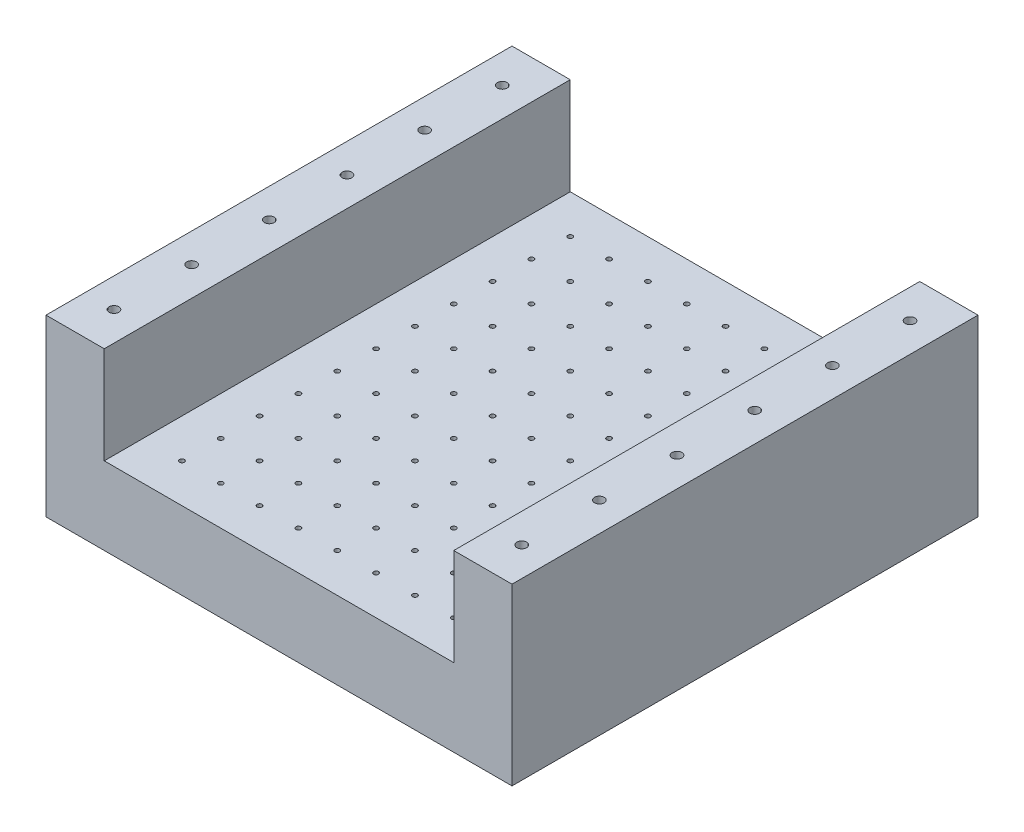
from build123d import *

# Parameters (mm, degrees)
SKETCH2_W           = 609.6
SKETCH2_H           = 609.6
BOSS_EXTRUDE1_DEPTH = 101.6
SKETCH4_W           = 76.2
SKETCH4_H           = 609.6
BOSS_EXTRUDE2_DEPTH = 127
SKETCH5_R           = 6.35
CUT_EXTRUDE1_DEPTH  = 50.8
LPATTERN1_COUNT     = 2
LPATTERN1_PITCH     = 533.4
SKETCH6_R           = 3.175
CUT_EXTRUDE2_DEPTH  = 50.8


with BuildPart() as part:
    # Sketch2 → Boss-Extrude1 (new body)
    with BuildSketch(Plane(origin=(0, 0, 0), x_dir=(1, 0, 0), z_dir=(0, 1, 0))):
        with Locations((408.853418399, -267.425277164)):
            Rectangle(SKETCH2_W, SKETCH2_H)
    extrude(amount=BOSS_EXTRUDE1_DEPTH)

    # Sketch4 → Boss-Extrude2 (add)
    with BuildSketch(Plane(origin=(0, 101.6, 0), x_dir=(1, 0, 0), z_dir=(0, 1, 0))):
        with Locations((142.153418399, -267.425277164)):
            Rectangle(SKETCH4_W, SKETCH4_H)
        with Locations((675.553418399, -267.425277164)):
            Rectangle(SKETCH4_W, SKETCH4_H)
    extrude(amount=BOSS_EXTRUDE2_DEPTH)

    # Sketch5 → Cut-Extrude1 (cut)
    with BuildSketch(Plane(origin=(0, 228.6, 0), x_dir=(1, 0, 0), z_dir=(0, 1, 0))):
        with Locations(Location((142.153418399, -13.425277164, 0), (0, 0, 270))):  # turned: the seam where the file's is
            Circle(SKETCH5_R)
        with Locations(Location((142.153418399, -115.025277164, 0), (0, 0, 270))):  # turned: the seam where the file's is
            Circle(SKETCH5_R)
        with Locations(Location((142.153418399, -216.625277164, 0), (0, 0, 270))):  # turned: the seam where the file's is
            Circle(SKETCH5_R)
        with Locations(Location((142.153418399, -318.225277164, 0), (0, 0, 270))):  # turned: the seam where the file's is
            Circle(SKETCH5_R)
        with Locations(Location((142.153418399, -419.825277164, 0), (0, 0, 270))):  # turned: the seam where the file's is
            Circle(SKETCH5_R)
        with Locations(Location((142.153418399, -521.425277164, 0), (0, 0, 270))):  # turned: the seam where the file's is
            Circle(SKETCH5_R)
    cut_extrude1 = extrude(amount=-CUT_EXTRUDE1_DEPTH, mode=Mode.SUBTRACT)

    # LPattern1: Cut-Extrude1 ×2
    with Locations(*[(i * LPATTERN1_PITCH, 0, 0) for i in range(1, LPATTERN1_COUNT)]):
        add(cut_extrude1, mode=Mode.SUBTRACT)

    # Sketch6 → Cut-Extrude2 (cut)
    with BuildSketch(Plane(origin=(0, 101.6, 0), x_dir=(1, 0, 0), z_dir=(0, 1, 0))):
        with Locations(Location((231.053418399, -521.425277164, 0), (0, 0, 270))):  # turned: the seam where the file's is
            Circle(SKETCH6_R)
        with Locations(Location((231.053418399, -470.625277164, 0), (0, 0, 270))):  # turned: the seam where the file's is
            Circle(SKETCH6_R)
        with Locations(Location((231.053418399, -419.825277164, 0), (0, 0, 270))):  # turned: the seam where the file's is
            Circle(SKETCH6_R)
        with Locations(Location((231.053418399, -369.025277164, 0), (0, 0, 270))):  # turned: the seam where the file's is
            Circle(SKETCH6_R)
        with Locations(Location((231.053418399, -318.225277164, 0), (0, 0, 270))):  # turned: the seam where the file's is
            Circle(SKETCH6_R)
        with Locations(Location((231.053418399, -267.425277164, 0), (0, 0, 270))):  # turned: the seam where the file's is
            Circle(SKETCH6_R)
        with Locations(Location((231.053418399, -216.625277164, 0), (0, 0, 270))):  # turned: the seam where the file's is
            Circle(SKETCH6_R)
        with Locations(Location((231.053418399, -165.825277164, 0), (0, 0, 270))):  # turned: the seam where the file's is
            Circle(SKETCH6_R)
        with Locations(Location((231.053418399, -115.025277164, 0), (0, 0, 270))):  # turned: the seam where the file's is
            Circle(SKETCH6_R)
        with Locations(Location((231.053418399, -64.225277164, 0), (0, 0, 270))):  # turned: the seam where the file's is
            Circle(SKETCH6_R)
        with Locations(Location((231.053418399, -13.425277164, 0), (0, 0, 270))):  # turned: the seam where the file's is
            Circle(SKETCH6_R)
        with Locations(Location((281.853418399, -521.425277164, 0), (0, 0, 270))):  # turned: the seam where the file's is
            Circle(SKETCH6_R)
        with Locations(Location((281.853418399, -470.625277164, 0), (0, 0, 270))):  # turned: the seam where the file's is
            Circle(SKETCH6_R)
        with Locations(Location((281.853418399, -419.825277164, 0), (0, 0, 270))):  # turned: the seam where the file's is
            Circle(SKETCH6_R)
        with Locations(Location((281.853418399, -369.025277164, 0), (0, 0, 270))):  # turned: the seam where the file's is
            Circle(SKETCH6_R)
        with Locations(Location((281.853418399, -318.225277164, 0), (0, 0, 270))):  # turned: the seam where the file's is
            Circle(SKETCH6_R)
        with Locations(Location((281.853418399, -267.425277164, 0), (0, 0, 270))):  # turned: the seam where the file's is
            Circle(SKETCH6_R)
        with Locations(Location((281.853418399, -216.625277164, 0), (0, 0, 270))):  # turned: the seam where the file's is
            Circle(SKETCH6_R)
        with Locations(Location((281.853418399, -165.825277164, 0), (0, 0, 270))):  # turned: the seam where the file's is
            Circle(SKETCH6_R)
        with Locations(Location((281.853418399, -115.025277164, 0), (0, 0, 270))):  # turned: the seam where the file's is
            Circle(SKETCH6_R)
        with Locations(Location((281.853418399, -64.225277164, 0), (0, 0, 270))):  # turned: the seam where the file's is
            Circle(SKETCH6_R)
        with Locations(Location((281.853418399, -13.425277164, 0), (0, 0, 270))):  # turned: the seam where the file's is
            Circle(SKETCH6_R)
        with Locations(Location((332.653418399, -521.425277164, 0), (0, 0, 270))):  # turned: the seam where the file's is
            Circle(SKETCH6_R)
        with Locations(Location((332.653418399, -470.625277164, 0), (0, 0, 270))):  # turned: the seam where the file's is
            Circle(SKETCH6_R)
        with Locations(Location((332.653418399, -419.825277164, 0), (0, 0, 270))):  # turned: the seam where the file's is
            Circle(SKETCH6_R)
        with Locations(Location((332.653418399, -369.025277164, 0), (0, 0, 270))):  # turned: the seam where the file's is
            Circle(SKETCH6_R)
        with Locations(Location((332.653418399, -318.225277164, 0), (0, 0, 270))):  # turned: the seam where the file's is
            Circle(SKETCH6_R)
        with Locations(Location((332.653418399, -267.425277164, 0), (0, 0, 270))):  # turned: the seam where the file's is
            Circle(SKETCH6_R)
        with Locations(Location((332.653418399, -216.625277164, 0), (0, 0, 270))):  # turned: the seam where the file's is
            Circle(SKETCH6_R)
        with Locations(Location((332.653418399, -165.825277164, 0), (0, 0, 270))):  # turned: the seam where the file's is
            Circle(SKETCH6_R)
        with Locations(Location((332.653418399, -115.025277164, 0), (0, 0, 270))):  # turned: the seam where the file's is
            Circle(SKETCH6_R)
        with Locations(Location((332.653418399, -64.225277164, 0), (0, 0, 270))):  # turned: the seam where the file's is
            Circle(SKETCH6_R)
        with Locations(Location((332.653418399, -13.425277164, 0), (0, 0, 270))):  # turned: the seam where the file's is
            Circle(SKETCH6_R)
        with Locations(Location((383.453418399, -521.425277164, 0), (0, 0, 270))):  # turned: the seam where the file's is
            Circle(SKETCH6_R)
        with Locations(Location((383.453418399, -470.625277164, 0), (0, 0, 270))):  # turned: the seam where the file's is
            Circle(SKETCH6_R)
        with Locations(Location((383.453418399, -419.825277164, 0), (0, 0, 270))):  # turned: the seam where the file's is
            Circle(SKETCH6_R)
        with Locations(Location((383.453418399, -369.025277164, 0), (0, 0, 270))):  # turned: the seam where the file's is
            Circle(SKETCH6_R)
        with Locations(Location((383.453418399, -318.225277164, 0), (0, 0, 270))):  # turned: the seam where the file's is
            Circle(SKETCH6_R)
        with Locations(Location((383.453418399, -267.425277164, 0), (0, 0, 270))):  # turned: the seam where the file's is
            Circle(SKETCH6_R)
        with Locations(Location((383.453418399, -216.625277164, 0), (0, 0, 270))):  # turned: the seam where the file's is
            Circle(SKETCH6_R)
        with Locations(Location((383.453418399, -165.825277164, 0), (0, 0, 270))):  # turned: the seam where the file's is
            Circle(SKETCH6_R)
        with Locations(Location((383.453418399, -115.025277164, 0), (0, 0, 270))):  # turned: the seam where the file's is
            Circle(SKETCH6_R)
        with Locations(Location((383.453418399, -64.225277164, 0), (0, 0, 270))):  # turned: the seam where the file's is
            Circle(SKETCH6_R)
        with Locations(Location((383.453418399, -13.425277164, 0), (0, 0, 270))):  # turned: the seam where the file's is
            Circle(SKETCH6_R)
        with Locations(Location((434.253418399, -521.425277164, 0), (0, 0, 270))):  # turned: the seam where the file's is
            Circle(SKETCH6_R)
        with Locations(Location((434.253418399, -470.625277164, 0), (0, 0, 270))):  # turned: the seam where the file's is
            Circle(SKETCH6_R)
        with Locations(Location((434.253418399, -419.825277164, 0), (0, 0, 270))):  # turned: the seam where the file's is
            Circle(SKETCH6_R)
        with Locations(Location((434.253418399, -369.025277164, 0), (0, 0, 270))):  # turned: the seam where the file's is
            Circle(SKETCH6_R)
        with Locations(Location((434.253418399, -318.225277164, 0), (0, 0, 270))):  # turned: the seam where the file's is
            Circle(SKETCH6_R)
        with Locations(Location((434.253418399, -267.425277164, 0), (0, 0, 270))):  # turned: the seam where the file's is
            Circle(SKETCH6_R)
        with Locations(Location((434.253418399, -216.625277164, 0), (0, 0, 270))):  # turned: the seam where the file's is
            Circle(SKETCH6_R)
        with Locations(Location((434.253418399, -165.825277164, 0), (0, 0, 270))):  # turned: the seam where the file's is
            Circle(SKETCH6_R)
        with Locations(Location((434.253418399, -115.025277164, 0), (0, 0, 270))):  # turned: the seam where the file's is
            Circle(SKETCH6_R)
        with Locations(Location((434.253418399, -64.225277164, 0), (0, 0, 270))):  # turned: the seam where the file's is
            Circle(SKETCH6_R)
        with Locations(Location((434.253418399, -13.425277164, 0), (0, 0, 270))):  # turned: the seam where the file's is
            Circle(SKETCH6_R)
        with Locations(Location((485.053418399, -521.425277164, 0), (0, 0, 270))):  # turned: the seam where the file's is
            Circle(SKETCH6_R)
        with Locations(Location((485.053418399, -470.625277164, 0), (0, 0, 270))):  # turned: the seam where the file's is
            Circle(SKETCH6_R)
        with Locations(Location((485.053418399, -419.825277164, 0), (0, 0, 270))):  # turned: the seam where the file's is
            Circle(SKETCH6_R)
        with Locations(Location((485.053418399, -369.025277164, 0), (0, 0, 270))):  # turned: the seam where the file's is
            Circle(SKETCH6_R)
        with Locations(Location((485.053418399, -318.225277164, 0), (0, 0, 270))):  # turned: the seam where the file's is
            Circle(SKETCH6_R)
        with Locations(Location((485.053418399, -267.425277164, 0), (0, 0, 270))):  # turned: the seam where the file's is
            Circle(SKETCH6_R)
        with Locations(Location((485.053418399, -216.625277164, 0), (0, 0, 270))):  # turned: the seam where the file's is
            Circle(SKETCH6_R)
        with Locations(Location((485.053418399, -165.825277164, 0), (0, 0, 270))):  # turned: the seam where the file's is
            Circle(SKETCH6_R)
        with Locations(Location((485.053418399, -115.025277164, 0), (0, 0, 270))):  # turned: the seam where the file's is
            Circle(SKETCH6_R)
        with Locations(Location((485.053418399, -64.225277164, 0), (0, 0, 270))):  # turned: the seam where the file's is
            Circle(SKETCH6_R)
        with Locations(Location((485.053418399, -13.425277164, 0), (0, 0, 270))):  # turned: the seam where the file's is
            Circle(SKETCH6_R)
        with Locations(Location((535.853418399, -521.425277164, 0), (0, 0, 270))):  # turned: the seam where the file's is
            Circle(SKETCH6_R)
        with Locations(Location((535.853418399, -470.625277164, 0), (0, 0, 270))):  # turned: the seam where the file's is
            Circle(SKETCH6_R)
        with Locations(Location((535.853418399, -419.825277164, 0), (0, 0, 270))):  # turned: the seam where the file's is
            Circle(SKETCH6_R)
        with Locations(Location((535.853418399, -369.025277164, 0), (0, 0, 270))):  # turned: the seam where the file's is
            Circle(SKETCH6_R)
        with Locations(Location((535.853418399, -318.225277164, 0), (0, 0, 270))):  # turned: the seam where the file's is
            Circle(SKETCH6_R)
        with Locations(Location((535.853418399, -267.425277164, 0), (0, 0, 270))):  # turned: the seam where the file's is
            Circle(SKETCH6_R)
        with Locations(Location((535.853418399, -216.625277164, 0), (0, 0, 270))):  # turned: the seam where the file's is
            Circle(SKETCH6_R)
        with Locations(Location((535.853418399, -165.825277164, 0), (0, 0, 270))):  # turned: the seam where the file's is
            Circle(SKETCH6_R)
        with Locations(Location((535.853418399, -115.025277164, 0), (0, 0, 270))):  # turned: the seam where the file's is
            Circle(SKETCH6_R)
        with Locations(Location((535.853418399, -64.225277164, 0), (0, 0, 270))):  # turned: the seam where the file's is
            Circle(SKETCH6_R)
        with Locations(Location((535.853418399, -13.425277164, 0), (0, 0, 270))):  # turned: the seam where the file's is
            Circle(SKETCH6_R)
        with Locations(Location((586.653418399, -521.425277164, 0), (0, 0, 270))):  # turned: the seam where the file's is
            Circle(SKETCH6_R)
        with Locations(Location((586.653418399, -470.625277164, 0), (0, 0, 270))):  # turned: the seam where the file's is
            Circle(SKETCH6_R)
        with Locations(Location((586.653418399, -419.825277164, 0), (0, 0, 270))):  # turned: the seam where the file's is
            Circle(SKETCH6_R)
        with Locations(Location((586.653418399, -369.025277164, 0), (0, 0, 270))):  # turned: the seam where the file's is
            Circle(SKETCH6_R)
        with Locations(Location((586.653418399, -318.225277164, 0), (0, 0, 270))):  # turned: the seam where the file's is
            Circle(SKETCH6_R)
        with Locations(Location((586.653418399, -267.425277164, 0), (0, 0, 270))):  # turned: the seam where the file's is
            Circle(SKETCH6_R)
        with Locations(Location((586.653418399, -216.625277164, 0), (0, 0, 270))):  # turned: the seam where the file's is
            Circle(SKETCH6_R)
        with Locations(Location((586.653418399, -165.825277164, 0), (0, 0, 270))):  # turned: the seam where the file's is
            Circle(SKETCH6_R)
        with Locations(Location((586.653418399, -115.025277164, 0), (0, 0, 270))):  # turned: the seam where the file's is
            Circle(SKETCH6_R)
        with Locations(Location((586.653418399, -64.225277164, 0), (0, 0, 270))):  # turned: the seam where the file's is
            Circle(SKETCH6_R)
        with Locations(Location((586.653418399, -13.425277164, 0), (0, 0, 270))):  # turned: the seam where the file's is
            Circle(SKETCH6_R)
    extrude(amount=-CUT_EXTRUDE2_DEPTH, mode=Mode.SUBTRACT)


solid = part.part
